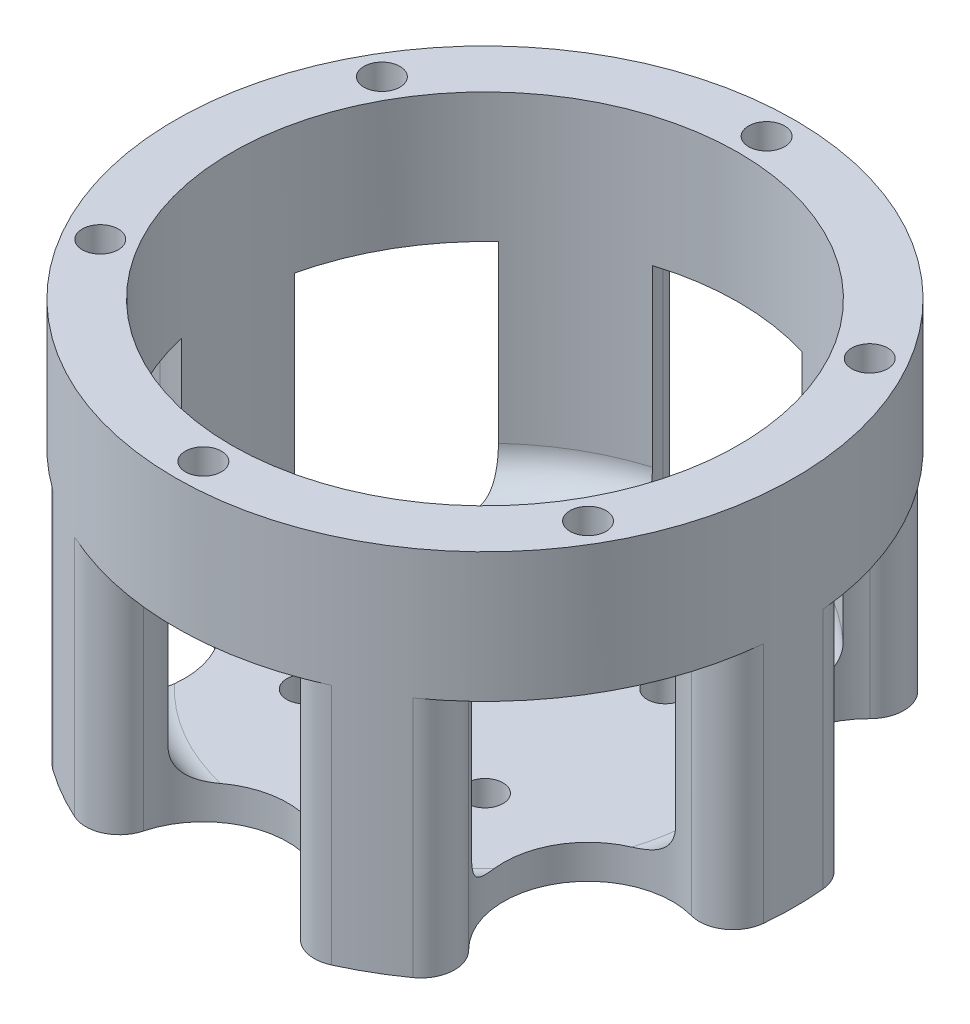
from build123d import *

# Parameters (mm, degrees)
SKETCH1_R                = 27.5
SKETCH1_R_2              = 1.6
BOSS_EXTRUDE1_DEPTH      = 33
SKETCH2_R                = 22.5
CUT_EXTRUDE1_DEPTH       = 30
SKETCH3_R                = 7.5
CUT_EXTRUDE2_DEPTH       = 21.5
FILLET1_R                = 3
CIRPATTERN1_COUNT        = 6
FILLET1_OF_CIRPATTERN1_R = 3
SKETCH5_R                = 1.6
CUT_EXTRUDE3_DEPTH       = 10
FILLET4_R                = 3


with BuildPart() as part:
    # Sketch1 → Boss-Extrude1 (new body)
    with BuildSketch(Plane(origin=(0, 0, 0), x_dir=(1, 0, 0), z_dir=(0, 1, 0))):
        Circle(SKETCH1_R)
        with Locations((0, 25)):
            Circle(SKETCH1_R_2, mode=Mode.SUBTRACT)
        with Locations((21.650635095, 12.5)):
            Circle(SKETCH1_R_2, mode=Mode.SUBTRACT)
        with Locations((21.650635095, -12.5)):
            Circle(SKETCH1_R_2, mode=Mode.SUBTRACT)
        with Locations((0, -25)):
            Circle(SKETCH1_R_2, mode=Mode.SUBTRACT)
        with Locations((-21.650635095, -12.5)):
            Circle(SKETCH1_R_2, mode=Mode.SUBTRACT)
        with Locations((-21.650635095, 12.5)):
            Circle(SKETCH1_R_2, mode=Mode.SUBTRACT)
    extrude(amount=BOSS_EXTRUDE1_DEPTH)

    # Sketch2 → Cut-Extrude1 (cut)
    with BuildSketch(Plane(origin=(0, 33, 0), x_dir=(1, 0, 0), z_dir=(0, 1, 0))):
        Circle(SKETCH2_R)
    extrude(amount=-CUT_EXTRUDE1_DEPTH, mode=Mode.SUBTRACT)

    # Sketch3 → Cut-Extrude2 (cut)
    with BuildSketch(Plane.XZ):
        with Locations((0, 25)):
            Circle(SKETCH3_R)
    cut_extrude2 = extrude(amount=-CUT_EXTRUDE2_DEPTH, mode=Mode.SUBTRACT)

    # Fillet1
    fillet1_edges = [part.edges().sort_by_distance(p)[0] for p in [
        (-7.348469228, 10.75, 26.5),
        (7.348469228, 10.75, 26.5),
    ]]
    fillet(fillet1_edges, radius=FILLET1_R)

    # CirPattern1: Cut-Extrude2 ×6 about axis
    cirpattern1_axis = Axis((0, 0, 0), (0, 1, 0))
    for i in range(1, CIRPATTERN1_COUNT):
        add(cut_extrude2.rotate(cirpattern1_axis, i * 360 / CIRPATTERN1_COUNT), mode=Mode.SUBTRACT)

    # Fillet1 of CirPattern1
    fillet1_of_cirpattern1_edges = [part.edges().sort_by_distance(p)[0] for p in [
        (19.275438586, 10.75, 19.613961031),
        (26.623907814, 10.75, 6.886038969),
        (26.623907814, 10.75, -6.886038969),
        (19.275438586, 10.75, -19.613961031),
        (7.348469228, 10.75, -26.5),
        (-7.348469228, 10.75, -26.5),
        (-19.275438586, 10.75, -19.613961031),
        (-26.623907814, 10.75, -6.886038969),
        (-26.623907814, 10.75, 6.886038969),
        (-19.275438586, 10.75, 19.613961031),
    ]]
    fillet(fillet1_of_cirpattern1_edges, radius=FILLET1_OF_CIRPATTERN1_R)

    # Sketch5 → Cut-Extrude3 (cut)
    with BuildSketch(Plane.XZ):
        with Locations((-8, 8)):
            Circle(SKETCH5_R)
        with Locations((8, 8)):
            Circle(SKETCH5_R)
        with Locations((8, -8)):
            Circle(SKETCH5_R)
        with Locations((-8, -8)):
            Circle(SKETCH5_R)
    extrude(amount=-CUT_EXTRUDE3_DEPTH, mode=Mode.SUBTRACT)

    # Fillet4
    fillet4_edges = [part.edges().sort_by_distance(p)[0] for p in [
        (11.25, 3, 19.485571585),
        (22.358598423, 3, 2.518546519),
        (11.25, 3, -19.485571585),
        (-11.25, 3, -19.485571585),
        (-22.5, 3, 0),
        (-11.25, 3, 19.485571585),
    ]]
    fillet(fillet4_edges, radius=FILLET4_R)


solid = part.part
